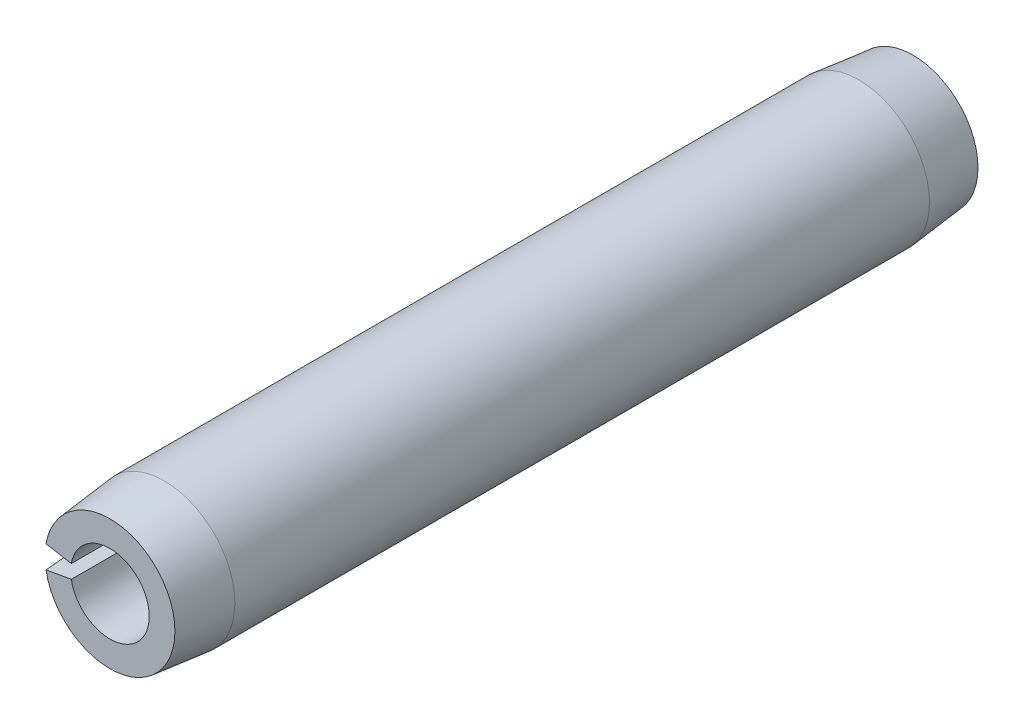
from build123d import *

# Parameters (mm, degrees)
EXTRUDE1_DEPTH = 7.14375


with BuildPart() as part:
    # Sketch1 → Extrude1 (new body, symmetric)
    with BuildSketch(Plane.XY):
        with BuildLine():
            Line((-1.238198788, 0.218327854), (-0.687888215, 0.121293252))
            ThreePointArc((-0.687888215, 0.121293252), (0.6985, 0), (-0.687888215, -0.121293252))
            Line((-0.687888215, -0.121293252), (-1.238198788, -0.218327854))
            ThreePointArc((-1.238198788, -0.218327854), (1.2573, 0), (-1.238198788, 0.218327854))
        make_face()
    extrude(amount=EXTRUDE1_DEPTH, both=True)

    # Sketch2 → Cut-Revolve1 (revolve, cut)
    with BuildSketch(Plane(origin=(0, 0, 0), x_dir=(0, 0, -1), z_dir=(1, 0, 0))):
        Polygon((7.14375, 1.2573), (7.14375, 1.1557), (6.17855, 1.2573), align=None)
        Polygon((-6.17855, 1.2573), (-7.14375, 1.2573), (-7.14375, 1.1557), align=None)
    revolve(axis=Axis((0, 0, -7.14375), (0, 0, 1)), mode=Mode.SUBTRACT)


solid = part.part
